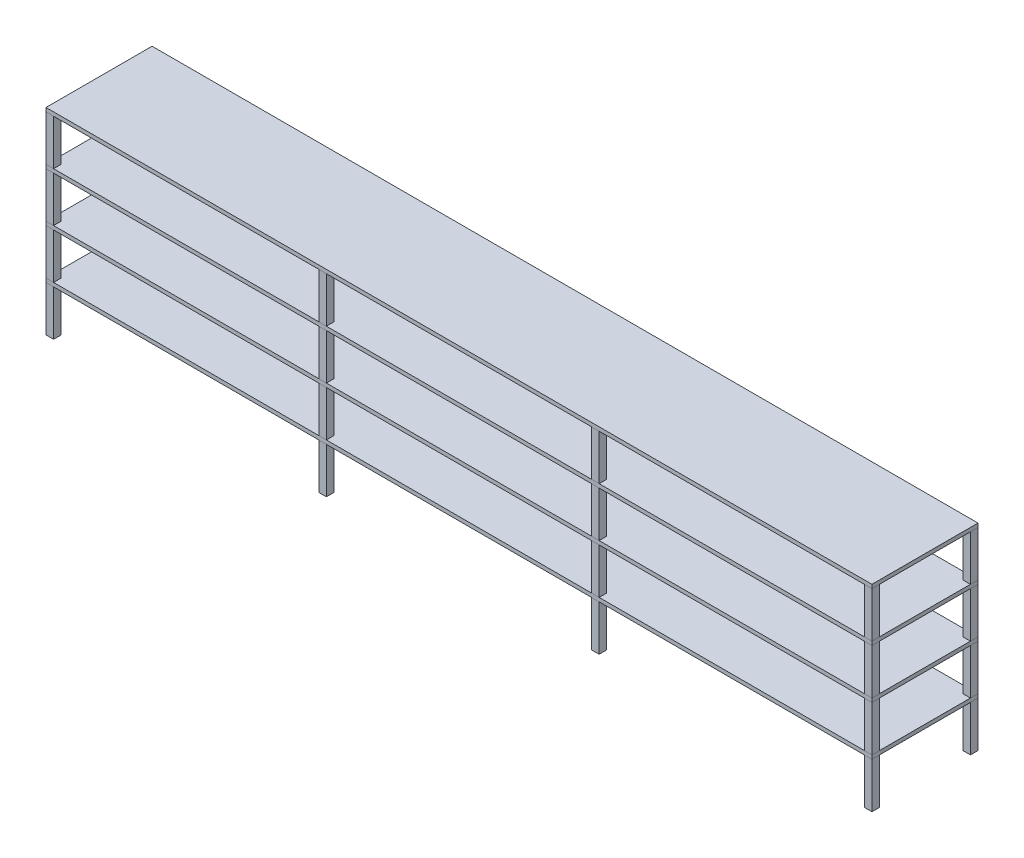
from build123d import *

# Parameters (mm, degrees)
SKETCH2_W        = 6.35
SKETCH2_H        = 6.35
EXTRUDE1_DEPTH   = 38.1
EXTRUDE1_2_DEPTH = 38.1
EXTRUDE1_3_DEPTH = 38.1
EXTRUDE1_4_DEPTH = 38.1
EXTRUDE1_5_DEPTH = 38.1
EXTRUDE1_6_DEPTH = 38.1
EXTRUDE1_7_DEPTH = 38.1
EXTRUDE1_8_DEPTH = 38.1
SKETCH3_W        = 692.15
SKETCH3_H        = 88.9
EXTRUDE2_DEPTH   = 3.175
LPATTERN1_COUNT  = 4
LPATTERN1_PITCH  = 41.275


with BuildPart() as part:
    # Sketch2 → Extrude1 (new body)
    with BuildSketch(Plane(origin=(0, 0, 0), x_dir=(1, 0, 0), z_dir=(0, 1, 0))):
        with Locations((-114.3, 41.275)):
            Rectangle(SKETCH2_W, SKETCH2_H)
    extrude(amount=EXTRUDE1_DEPTH)


with BuildPart() as body_2:
    # Sketch2 → Extrude1 2 (new body)
    with BuildSketch(Plane(origin=(0, 0, 0), x_dir=(1, 0, 0), z_dir=(0, 1, 0))):
        with Locations((-342.9, -41.275)):
            Rectangle(SKETCH2_W, SKETCH2_H)
    extrude(amount=EXTRUDE1_2_DEPTH)


with BuildPart() as body_3:
    # Sketch2 → Extrude1 3 (new body)
    with BuildSketch(Plane(origin=(0, 0, 0), x_dir=(1, 0, 0), z_dir=(0, 1, 0))):
        with Locations((-342.9, 41.275)):
            Rectangle(SKETCH2_W, SKETCH2_H)
    extrude(amount=EXTRUDE1_3_DEPTH)


with BuildPart() as body_4:
    # Sketch2 → Extrude1 4 (new body)
    with BuildSketch(Plane(origin=(0, 0, 0), x_dir=(1, 0, 0), z_dir=(0, 1, 0))):
        with Locations((-114.3, -41.275)):
            Rectangle(SKETCH2_W, SKETCH2_H)
    extrude(amount=EXTRUDE1_4_DEPTH)


with BuildPart() as body_5:
    # Sketch2 → Extrude1 5 (new body)
    with BuildSketch(Plane(origin=(0, 0, 0), x_dir=(1, 0, 0), z_dir=(0, 1, 0))):
        with Locations((114.3, 41.275)):
            Rectangle(SKETCH2_W, SKETCH2_H)
    extrude(amount=EXTRUDE1_5_DEPTH)


with BuildPart() as body_6:
    # Sketch2 → Extrude1 6 (new body)
    with BuildSketch(Plane(origin=(0, 0, 0), x_dir=(1, 0, 0), z_dir=(0, 1, 0))):
        with Locations((114.3, -41.275)):
            Rectangle(SKETCH2_W, SKETCH2_H)
    extrude(amount=EXTRUDE1_6_DEPTH)


with BuildPart() as body_7:
    # Sketch2 → Extrude1 7 (new body)
    with BuildSketch(Plane(origin=(0, 0, 0), x_dir=(1, 0, 0), z_dir=(0, 1, 0))):
        with Locations((342.9, 41.275)):
            Rectangle(SKETCH2_W, SKETCH2_H)
    extrude(amount=EXTRUDE1_7_DEPTH)


with BuildPart() as body_8:
    # Sketch2 → Extrude1 8 (new body)
    with BuildSketch(Plane(origin=(0, 0, 0), x_dir=(1, 0, 0), z_dir=(0, 1, 0))):
        with Locations((342.9, -41.275)):
            Rectangle(SKETCH2_W, SKETCH2_H)
    extrude(amount=EXTRUDE1_8_DEPTH)


with BuildPart() as body_9:
    # Sketch3 → Extrude2 (new body)
    with BuildSketch(Plane(origin=(0, 38.1, 0), x_dir=(1, 0, 0), z_dir=(0, 1, 0))):
        Rectangle(SKETCH3_W, SKETCH3_H)
    extrude(amount=EXTRUDE2_DEPTH)


with BuildPart() as lpattern1_1:
    # LPattern1: pattern copy
    add(body_2.part.moved(Location(Vector(0, 1, 0) * (1 * LPATTERN1_PITCH))))


with BuildPart() as lpattern1_2:
    # LPattern1: pattern copy
    add(body_2.part.moved(Location(Vector(0, 1, 0) * (2 * LPATTERN1_PITCH))))


with BuildPart() as lpattern1_3:
    # LPattern1: pattern copy
    add(body_2.part.moved(Location(Vector(0, 1, 0) * (3 * LPATTERN1_PITCH))))


with BuildPart() as lpattern1_4:
    # LPattern1: pattern copy
    add(body_3.part.moved(Location(Vector(0, 1, 0) * (1 * LPATTERN1_PITCH))))


with BuildPart() as lpattern1_5:
    # LPattern1: pattern copy
    add(body_3.part.moved(Location(Vector(0, 1, 0) * (2 * LPATTERN1_PITCH))))


with BuildPart() as lpattern1_6:
    # LPattern1: pattern copy
    add(body_3.part.moved(Location(Vector(0, 1, 0) * (3 * LPATTERN1_PITCH))))


with BuildPart() as lpattern1_7:
    # LPattern1: pattern copy
    add(body_4.part.moved(Location(Vector(0, 1, 0) * (1 * LPATTERN1_PITCH))))


with BuildPart() as lpattern1_8:
    # LPattern1: pattern copy
    add(body_4.part.moved(Location(Vector(0, 1, 0) * (2 * LPATTERN1_PITCH))))


with BuildPart() as lpattern1_9:
    # LPattern1: pattern copy
    add(body_4.part.moved(Location(Vector(0, 1, 0) * (3 * LPATTERN1_PITCH))))


with BuildPart() as lpattern1_10:
    # LPattern1: pattern copy
    add(part.part.moved(Location(Vector(0, 1, 0) * (1 * LPATTERN1_PITCH))))


with BuildPart() as lpattern1_11:
    # LPattern1: pattern copy
    add(part.part.moved(Location(Vector(0, 1, 0) * (2 * LPATTERN1_PITCH))))


with BuildPart() as lpattern1_12:
    # LPattern1: pattern copy
    add(part.part.moved(Location(Vector(0, 1, 0) * (3 * LPATTERN1_PITCH))))


with BuildPart() as lpattern1_13:
    # LPattern1: pattern copy
    add(body_6.part.moved(Location(Vector(0, 1, 0) * (1 * LPATTERN1_PITCH))))


with BuildPart() as lpattern1_14:
    # LPattern1: pattern copy
    add(body_6.part.moved(Location(Vector(0, 1, 0) * (2 * LPATTERN1_PITCH))))


with BuildPart() as lpattern1_15:
    # LPattern1: pattern copy
    add(body_6.part.moved(Location(Vector(0, 1, 0) * (3 * LPATTERN1_PITCH))))


with BuildPart() as lpattern1_16:
    # LPattern1: pattern copy
    add(body_5.part.moved(Location(Vector(0, 1, 0) * (1 * LPATTERN1_PITCH))))


with BuildPart() as lpattern1_17:
    # LPattern1: pattern copy
    add(body_5.part.moved(Location(Vector(0, 1, 0) * (2 * LPATTERN1_PITCH))))


with BuildPart() as lpattern1_18:
    # LPattern1: pattern copy
    add(body_5.part.moved(Location(Vector(0, 1, 0) * (3 * LPATTERN1_PITCH))))


with BuildPart() as lpattern1_19:
    # LPattern1: pattern copy
    add(body_9.part.moved(Location(Vector(0, 1, 0) * (1 * LPATTERN1_PITCH))))


with BuildPart() as lpattern1_20:
    # LPattern1: pattern copy
    add(body_9.part.moved(Location(Vector(0, 1, 0) * (2 * LPATTERN1_PITCH))))


with BuildPart() as lpattern1_21:
    # LPattern1: pattern copy
    add(body_9.part.moved(Location(Vector(0, 1, 0) * (3 * LPATTERN1_PITCH))))


with BuildPart() as lpattern1_22:
    # LPattern1: pattern copy
    add(body_8.part.moved(Location(Vector(0, 1, 0) * (1 * LPATTERN1_PITCH))))


with BuildPart() as lpattern1_23:
    # LPattern1: pattern copy
    add(body_8.part.moved(Location(Vector(0, 1, 0) * (2 * LPATTERN1_PITCH))))


with BuildPart() as lpattern1_24:
    # LPattern1: pattern copy
    add(body_8.part.moved(Location(Vector(0, 1, 0) * (3 * LPATTERN1_PITCH))))


with BuildPart() as lpattern1_25:
    # LPattern1: pattern copy
    add(body_7.part.moved(Location(Vector(0, 1, 0) * (1 * LPATTERN1_PITCH))))


with BuildPart() as lpattern1_26:
    # LPattern1: pattern copy
    add(body_7.part.moved(Location(Vector(0, 1, 0) * (2 * LPATTERN1_PITCH))))


with BuildPart() as lpattern1_27:
    # LPattern1: pattern copy
    add(body_7.part.moved(Location(Vector(0, 1, 0) * (3 * LPATTERN1_PITCH))))


solid = Compound([part.part, body_2.part, body_3.part, body_4.part, body_5.part, body_6.part, body_7.part, body_8.part, body_9.part, lpattern1_1.part, lpattern1_2.part, lpattern1_3.part, lpattern1_4.part, lpattern1_5.part, lpattern1_6.part, lpattern1_7.part, lpattern1_8.part, lpattern1_9.part, lpattern1_10.part, lpattern1_11.part, lpattern1_12.part, lpattern1_13.part, lpattern1_14.part, lpattern1_15.part, lpattern1_16.part, lpattern1_17.part, lpattern1_18.part, lpattern1_19.part, lpattern1_20.part, lpattern1_21.part, lpattern1_22.part, lpattern1_23.part, lpattern1_24.part, lpattern1_25.part, lpattern1_26.part, lpattern1_27.part])
